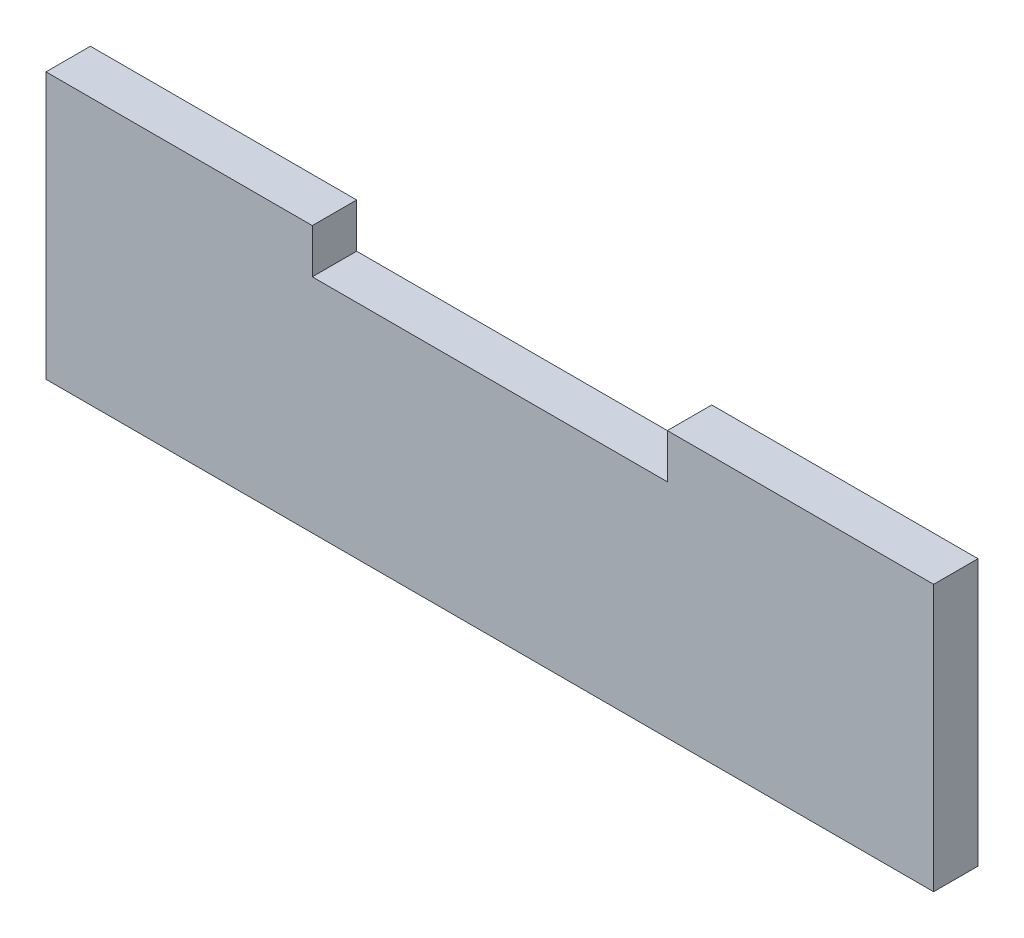
from build123d import *

# Parameters (mm, degrees)
BOSS_EXTRUDE1_DEPTH = 5


with BuildPart() as part:
    # Sketch1 → Boss-Extrude1 (new body)
    with BuildSketch(Plane.XY):
        Polygon((-50, -15), (50, -15), (50, 15), (20, 15), (20, 10), (-20, 10), (-20, 15), (-50, 15), align=None)
    extrude(amount=BOSS_EXTRUDE1_DEPTH)


solid = part.part
